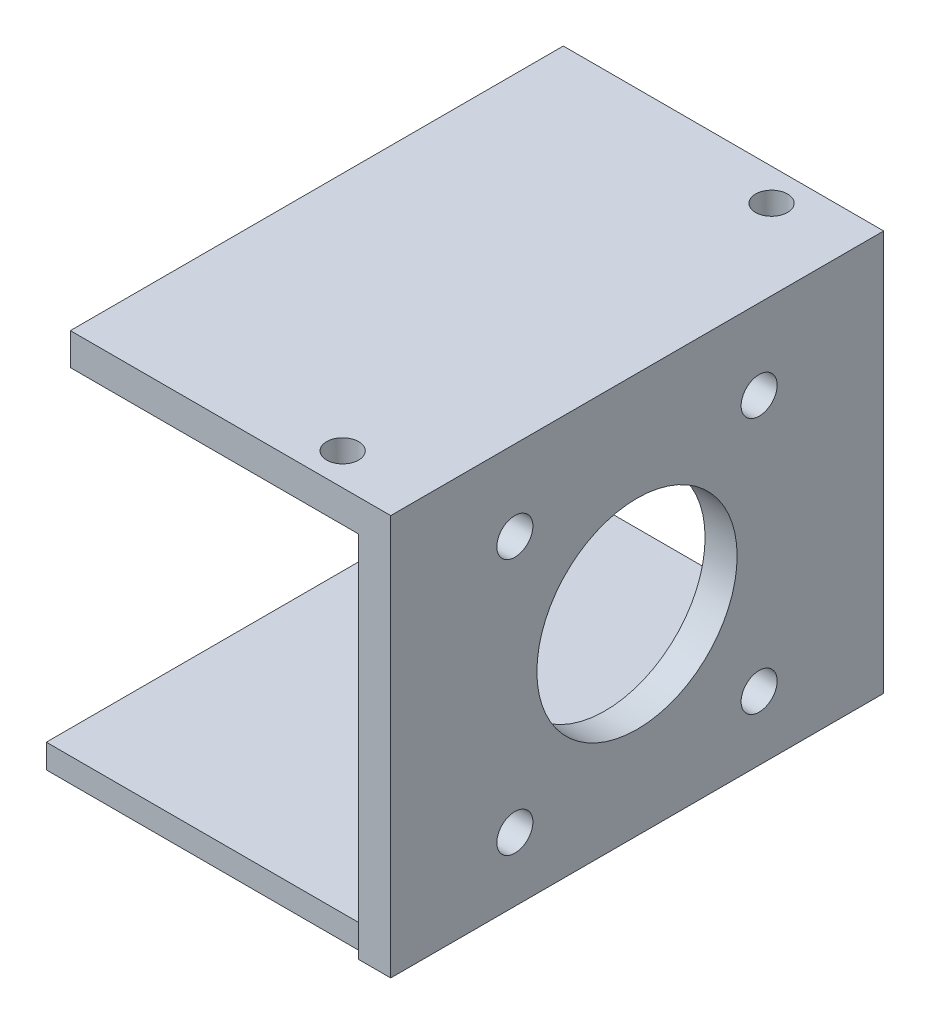
from build123d import *

# Parameters (mm, degrees)
CROQUIS1_W              = 40
CROQUIS1_H              = 41.5
CROQUIS1_R              = 2.5
SALIENTE_EXTRUIR1_DEPTH = 3
CROQUIS2_W              = 4
CROQUIS2_H              = 41.5
SALIENTE_EXTRUIR2_DEPTH = 45
CORTAR_EXTRUIR1_START   = 44
CROQUIS3_R              = 12.5
CROQUIS3_R_2            = 2.25
CORTAR_EXTRUIR1_DEPTH   = 4
SALIENTE_EXTRUIR4_START = 40
SALIENTE_EXTRUIR4_DEPTH = 4
CROQUIS6_W              = 40
CROQUIS6_H              = 9.5
CROQUIS6_H_2            = 9
SALIENTE_EXTRUIR5_DEPTH = 3
SALIENTE_EXTRUIR6_START = 46
CROQUIS7_W              = 40
CROQUIS7_H              = 61.549056497
CROQUIS7_R              = 2
SALIENTE_EXTRUIR6_DEPTH = 4


with BuildPart() as part:
    # Croquis1 → Saliente-Extruir1 (new body)
    with BuildSketch(Plane(origin=(0, 0, 0), x_dir=(1, 0, 0), z_dir=(0, 1, 0))):
        with Locations((20, -0.25)):
            Rectangle(CROQUIS1_W, CROQUIS1_H)
        with Locations((33.75, 14.25)):
            Circle(CROQUIS1_R, mode=Mode.SUBTRACT)
        with Locations((33.75, -14.75)):
            Circle(CROQUIS1_R, mode=Mode.SUBTRACT)
    extrude(amount=SALIENTE_EXTRUIR1_DEPTH)

    # Croquis2 → Saliente-Extruir2 (add)
    with BuildSketch(Plane(origin=(0, 0, 0), x_dir=(1, 0, 0), z_dir=(0, 1, 0))):
        with Locations((42, -0.25)):
            Rectangle(CROQUIS2_W, CROQUIS2_H)
    extrude(amount=SALIENTE_EXTRUIR2_DEPTH)

    # Croquis3 → Cortar-Extruir1 (cut)
    with BuildSketch(Plane(origin=(0, 0, 0), x_dir=(0, 0, -1), z_dir=(1, 0, 0)).offset(CORTAR_EXTRUIR1_START)):
        with Locations((-0.25, 24)):
            Circle(CROQUIS3_R)
        with Locations((15, 40)):
            Circle(CROQUIS3_R_2)
        with Locations((-15.5, 40)):
            Circle(CROQUIS3_R_2)
        with Locations((-15.5, 8)):
            Circle(CROQUIS3_R_2)
        with Locations((15, 8)):
            Circle(CROQUIS3_R_2)
    extrude(amount=-CORTAR_EXTRUIR1_DEPTH, mode=Mode.SUBTRACT)

    # Croquis5 → Saliente-Extruir4 (add)
    with BuildSketch(Plane(origin=(0, 0, 0), x_dir=(0, 0, -1), z_dir=(1, 0, 0)).offset(SALIENTE_EXTRUIR4_START)):
        Polygon((-21, 0), (-31, 0), (-31, 46), (30.549056497, 46), (30.5, 2.6158e-05), (20.5, 2.6158e-05), (20.5, 45), (-21, 45), align=None)
    extrude(amount=SALIENTE_EXTRUIR4_DEPTH)

    # Croquis6 → Saliente-Extruir5 (add)
    with BuildSketch(Plane(origin=(0, 0, 0), x_dir=(1, 0, 0), z_dir=(0, 1, 0))):
        with Locations((20, 25.25)):
            Rectangle(CROQUIS6_W, CROQUIS6_H)
        with Locations((20, -25.5)):
            Rectangle(CROQUIS6_W, CROQUIS6_H_2)
    extrude(amount=SALIENTE_EXTRUIR5_DEPTH)

    # Croquis7 → Saliente-Extruir6 (add)
    with BuildSketch(Plane(origin=(0, 0, 0), x_dir=(1, 0, 0), z_dir=(0, 1, 0)).offset(SALIENTE_EXTRUIR6_START)):
        with Locations((24, -0.225471752)):
            Rectangle(CROQUIS7_W, CROQUIS7_H)
        with Locations((34, 26.549056497)):
            Circle(CROQUIS7_R, mode=Mode.SUBTRACT)
        with Locations((34, -27)):
            Circle(CROQUIS7_R, mode=Mode.SUBTRACT)
    extrude(amount=SALIENTE_EXTRUIR6_DEPTH)


solid = part.part
